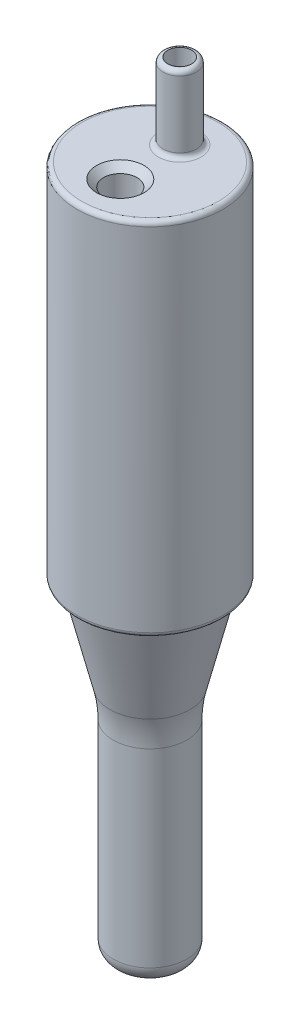
from build123d import *

# Parameters (mm, degrees)
SKETCH_2_R          = 1.785
SKETCH_2_R_2        = 1.27
EXTRUDE_2_DEPTH     = 8.13
FILLET_1_R          = 0.5
FILLET_2_R          = 0.5
FILLET_3_R          = 0.5
SKETCH_5_R          = 1.785
CUT_EXTRUDE_1_DEPTH = 18
CHAMFER_1_SIZE      = 0.75


with BuildPart() as part:
    # Эскиз1 → Повернуть1 (revolve)
    with BuildSketch(Plane(origin=(0, 0, 0), x_dir=(0, 0, -1), z_dir=(1, 0, 0))):
        with BuildLine():
            Line((7.81, 0), (7.81, 38.61))
            Line((7.81, 38.61), (0, 38.61))
            Line((0, 38.61), (0, -34.919667125))
            Line((0, -34.919667125), (2.135124109, -34.919667125))
            Line((2.135124109, -34.919667125), (2.913509872, -34.919667125))
            ThreePointArc((2.913509872, -34.919667125), (3.658458343, -34.255552274), (3.935124109, -33.296671252))
            Line((3.935124109, -33.296671252), (3.935124109, -13.000030341))
            ThreePointArc((3.935124109, -13.000030341), (4.018123706, -11.486391771), (4.28668668, -9.994458602))
            Line((4.28668668, -9.994458602), (6.73, 0))
            Line((6.73, 0), (7.81, 0))
        make_face()
    revolve(axis=Axis((0, -34.919667125, 0), (0, 1, 0)))

    # Эскиз2 → Бобышка-Вытянуть2 (add)
    with BuildSketch(Plane(origin=(0, 38.61, 0), x_dir=(1, 0, 0), z_dir=(0, 1, 0))):
        with Locations((0, 3.18)):
            Circle(SKETCH_2_R)
        with Locations((0, 3.18)):
            Circle(SKETCH_2_R_2, mode=Mode.SUBTRACT)
    extrude(amount=EXTRUDE_2_DEPTH)

    # Скругление1
    fillet_1_edges = [part.edges().sort_by_distance(p)[0] for p in [
        (-1.785, 46.74, -3.18),
    ]]
    fillet(fillet_1_edges, radius=FILLET_1_R)

    # Скругление2
    fillet_2_edges = [part.edges().sort_by_distance(p)[0] for p in [
        (-1.785, 38.61, -3.18),
    ]]
    fillet(fillet_2_edges, radius=FILLET_2_R)

    # Скругление3
    fillet_3_edges = [part.edges().sort_by_distance(p)[0] for p in [
        (0, 38.61, 7.81),
        (0, 0, 7.81),
    ]]
    fillet(fillet_3_edges, radius=FILLET_3_R)

    # Эскиз5 → Вырез-Вытянуть1 (cut)
    with BuildSketch(Plane(origin=(0, 39.61, 0), x_dir=(1, 0, 0), z_dir=(0, 1, 0))):
        with Locations((0, -3.18)):
            Circle(SKETCH_5_R)
    extrude(amount=-CUT_EXTRUDE_1_DEPTH, mode=Mode.SUBTRACT)

    # Фаска1
    chamfer_1_edges = [part.edges().sort_by_distance(p)[0] for p in [
        (-1.785, 38.61, 3.18),
    ]]
    chamfer(chamfer_1_edges, length=CHAMFER_1_SIZE)


solid = part.part
